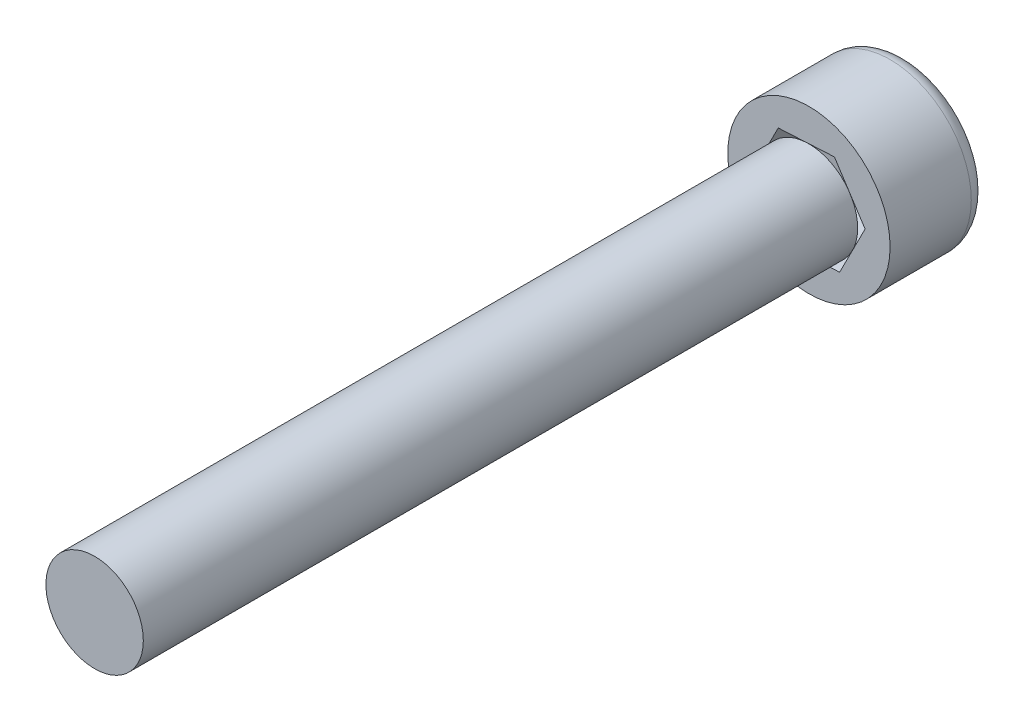
from build123d import *

# Parameters (mm, degrees)
SKETCH1_R           = 2.5
BOSS_EXTRUDE1_DEPTH = 3
SKETCH2_R           = 1.5
BOSS_EXTRUDE2_DEPTH = 22
CUT_EXTRUDE1_DEPTH  = 3
FILLET1_R           = 0.5


with BuildPart() as part:
    # Sketch1 → Boss-Extrude1 (new body)
    with BuildSketch(Plane.XY):
        Circle(SKETCH1_R)
    extrude(amount=BOSS_EXTRUDE1_DEPTH)

    # Sketch2 → Boss-Extrude2 (add)
    with BuildSketch(Plane.XY.offset(3)):
        Circle(SKETCH2_R)
    extrude(amount=BOSS_EXTRUDE2_DEPTH)

    # Sketch3 → Cut-Extrude1 (cut)
    with BuildSketch(Plane(origin=(0, 0, 0), x_dir=(-1, 0, 0), z_dir=(0, 0, -1))):
        Polygon((0.784462107, -1.544221229), (1.729565866, -0.092746502), (0.94510376, 1.451474727), (-0.784462107, 1.544221229), (-1.729565866, 0.092746502), (-0.94510376, -1.451474727), align=None)
    extrude(amount=-CUT_EXTRUDE1_DEPTH, mode=Mode.SUBTRACT)

    # Fillet1
    fillet1_edges = [part.edges().sort_by_distance(p)[0] for p in [
        (-2.5, 0, 0),
    ]]
    fillet(fillet1_edges, radius=FILLET1_R)


solid = part.part
